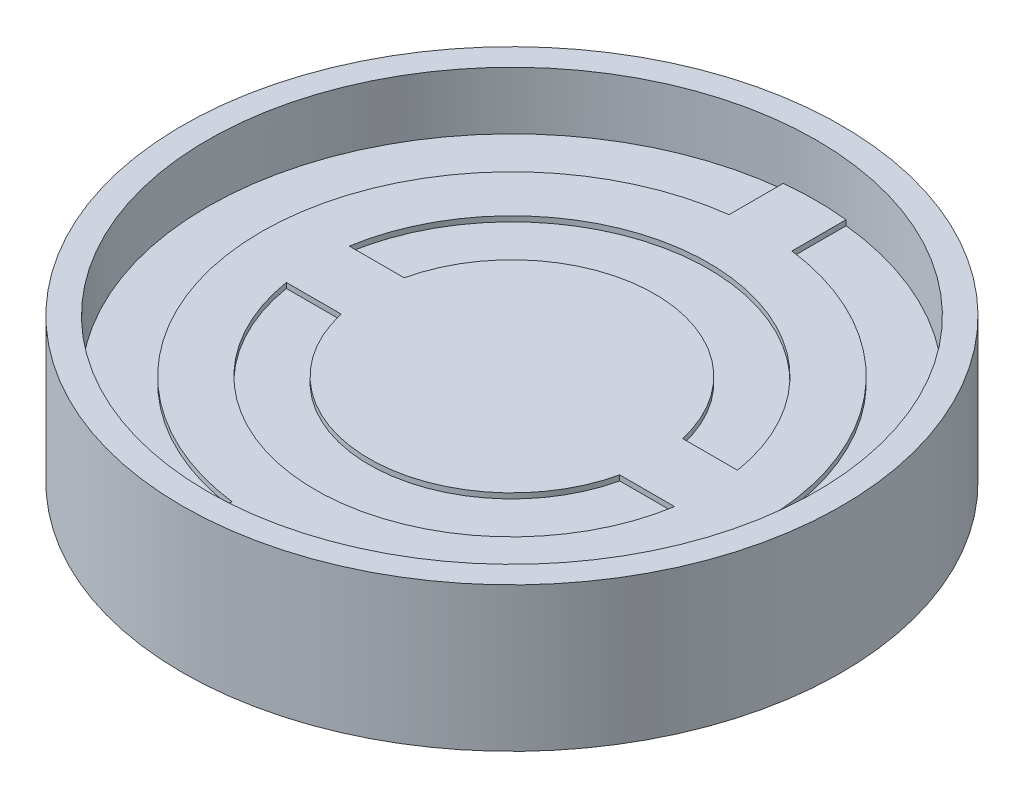
from build123d import *

# Parameters (mm, degrees)
SKETCH1_R           = 15.9639
BOSS_EXTRUDE1_DEPTH = 3.4925
SKETCH2_R           = 14.7447
CUT_EXTRUDE1_DEPTH  = 2.794
BOSS_EXTRUDE2_DEPTH = 0.254


with BuildPart() as part:
    # Sketch1 → Boss-Extrude1 (new body, symmetric)
    with BuildSketch(Plane(origin=(0, 0, 0), x_dir=(1, 0, 0), z_dir=(0, 1, 0))):
        Circle(SKETCH1_R)
    extrude(amount=BOSS_EXTRUDE1_DEPTH, both=True)

    # Sketch2 → Cut-Extrude1 (cut)
    with BuildSketch(Plane(origin=(0, 3.4925, 0), x_dir=(1, 0, 0), z_dir=(0, 1, 0))):
        Circle(SKETCH2_R)
    cut_extrude1 = extrude(amount=-CUT_EXTRUDE1_DEPTH, mode=Mode.SUBTRACT)

    # Sketch3 → Boss-Extrude2 (add)
    with BuildSketch(Plane(origin=(0, 0.6985, 0), x_dir=(1, 0, 0), z_dir=(0, 1, 0))):
        with BuildLine():
            ThreePointArc((6.745125909, 1.524), (0, 6.91515), (-6.745125909, 1.524))
            Line((-6.745125909, 1.524), (-6.745125909, -1.524))
            ThreePointArc((-6.745125909, -1.524), (0, -6.91515), (6.745125909, -1.524))
            Line((6.745125909, -1.524), (6.745125909, 1.524))
        make_face()
        with BuildLine():
            ThreePointArc((-12.038771055, -1.524), (-8.580634724, -8.580634724), (-1.524, -12.038771055))
            Line((-1.524, -12.038771055), (1.524, -12.038771055))
            ThreePointArc((1.524, -12.038771055), (8.580634724, -8.580634724), (12.038771055, -1.524))
            Line((12.038771055, -1.524), (9.402289562, -1.524))
            ThreePointArc((9.402289562, -1.524), (0, -9.525), (-9.402289562, -1.524))
            Line((-9.402289562, -1.524), (-12.038771055, -1.524))
        make_face()
        with BuildLine():
            Line((1.524, 12.038771055), (-1.524, 12.038771055))
            ThreePointArc((-1.524, 12.038771055), (-8.580634724, 8.580634724), (-12.038771055, 1.524))
            Line((-12.038771055, 1.524), (-9.402289562, 1.524))
            ThreePointArc((-9.402289562, 1.524), (0, 9.525), (9.402289562, 1.524))
            Line((9.402289562, 1.524), (12.038771055, 1.524))
            ThreePointArc((12.038771055, 1.524), (8.580634724, 8.580634724), (1.524, 12.038771055))
        make_face()
        with BuildLine():
            ThreePointArc((1.524, 14.665728829), (0, 14.7447), (-1.524, 14.665728829))
            Line((-1.524, 14.665728829), (-1.524, 12.038771055))
            ThreePointArc((-1.524, 12.038771055), (0, 12.13485), (1.524, 12.038771055))
            Line((1.524, 12.038771055), (1.524, 14.665728829))
        make_face()
        with BuildLine():
            Line((-6.745125909, 1.524), (-9.402289562, 1.524))
            ThreePointArc((-9.402289562, 1.524), (-9.525, 0), (-9.402289562, -1.524))
            Line((-9.402289562, -1.524), (-6.745125909, -1.524))
            ThreePointArc((-6.745125909, -1.524), (-6.91515, 0), (-6.745125909, 1.524))
        make_face()
        with BuildLine():
            ThreePointArc((9.525, 0), (9.494272828, 0.764466129), (9.402289562, 1.524))
            Line((9.402289562, 1.524), (6.745125909, 1.524))
            ThreePointArc((6.745125909, 1.524), (6.87251253, 0.766727493), (6.91515, 0))
            ThreePointArc((6.91515, 0), (6.87251253, -0.766727493), (6.745125909, -1.524))
            Line((6.745125909, -1.524), (9.402289562, -1.524))
            ThreePointArc((9.402289562, -1.524), (9.494272828, -0.764466129), (9.525, 0))
        make_face()
        with BuildLine():
            Line((-1.524, -12.038771055), (-1.524, -14.665728829))
            ThreePointArc((-1.524, -14.665728829), (0, -14.7447), (1.524, -14.665728829))
            Line((1.524, -14.665728829), (1.524, -12.038771055))
            ThreePointArc((1.524, -12.038771055), (0, -12.13485), (-1.524, -12.038771055))
        make_face()
        with BuildLine():
            Line((-9.402289562, 1.524), (-12.038771055, 1.524))
            Line((-12.038771055, 1.524), (-12.038771055, -1.524))
            Line((-12.038771055, -1.524), (-9.402289562, -1.524))
            ThreePointArc((-9.402289562, -1.524), (-9.525, 0), (-9.402289562, 1.524))
        make_face()
        with BuildLine():
            Line((12.038771055, -1.524), (12.038771055, 1.524))
            Line((12.038771055, 1.524), (9.402289562, 1.524))
            ThreePointArc((9.402289562, 1.524), (9.494272828, 0.764466129), (9.525, 0))
            ThreePointArc((9.525, 0), (9.494272828, -0.764466129), (9.402289562, -1.524))
            Line((9.402289562, -1.524), (12.038771055, -1.524))
        make_face()
        with BuildLine():
            ThreePointArc((12.13485, 0), (12.110806444, 0.763512797), (12.038771055, 1.524))
            Line((12.038771055, 1.524), (12.038771055, -1.524))
            ThreePointArc((12.038771055, -1.524), (12.110806444, -0.763512797), (12.13485, 0))
        make_face()
        with BuildLine():
            ThreePointArc((6.91515, 0), (6.87251253, 0.766727493), (6.745125909, 1.524))
            Line((6.745125909, 1.524), (6.745125909, -1.524))
            ThreePointArc((6.745125909, -1.524), (6.87251253, -0.766727493), (6.91515, 0))
        make_face()
        with BuildLine():
            Line((-6.745125909, -1.524), (-6.745125909, 1.524))
            ThreePointArc((-6.745125909, 1.524), (-6.91515, 0), (-6.745125909, -1.524))
        make_face()
        with BuildLine():
            Line((-12.038771055, -1.524), (-12.038771055, 1.524))
            ThreePointArc((-12.038771055, 1.524), (-12.13485, 0), (-12.038771055, -1.524))
        make_face()
        with BuildLine():
            Line((1.524, -12.038771055), (-1.524, -12.038771055))
            ThreePointArc((-1.524, -12.038771055), (0, -12.13485), (1.524, -12.038771055))
        make_face()
        with BuildLine():
            ThreePointArc((1.524, 12.038771055), (0, 12.13485), (-1.524, 12.038771055))
            Line((-1.524, 12.038771055), (1.524, 12.038771055))
        make_face()
    boss_extrude2 = extrude(amount=BOSS_EXTRUDE2_DEPTH)

    # Mirror1: Cut-Extrude1, Boss-Extrude2 across plane
    add(cut_extrude1.mirror(Plane.ZX), mode=Mode.SUBTRACT)
    add(boss_extrude2.mirror(Plane.ZX))


solid = part.part
